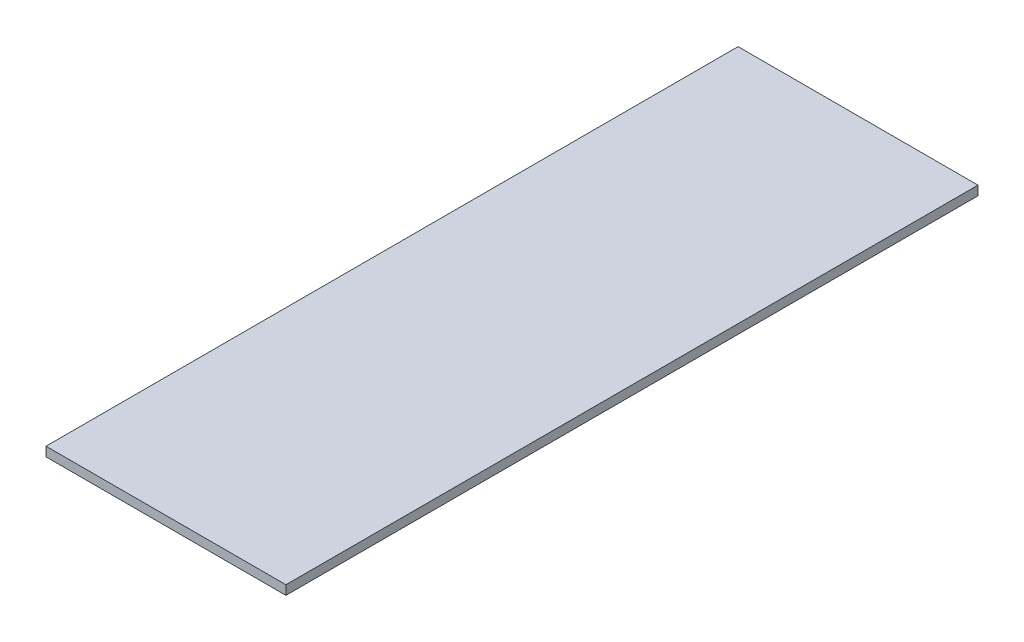
from build123d import *

# Parameters (mm, degrees)
SKETCH1_W           = 26
SKETCH1_H           = 75
BOSS_EXTRUDE1_DEPTH = 1


with BuildPart() as part:
    # Sketch1 → Boss-Extrude1 (new body)
    with BuildSketch(Plane(origin=(0, 25.5, 0), x_dir=(1, 0, 0), z_dir=(0, 1, 0))):
        with Locations((0, -7.5)):
            Rectangle(SKETCH1_W, SKETCH1_H)
    extrude(amount=BOSS_EXTRUDE1_DEPTH)


solid = part.part
